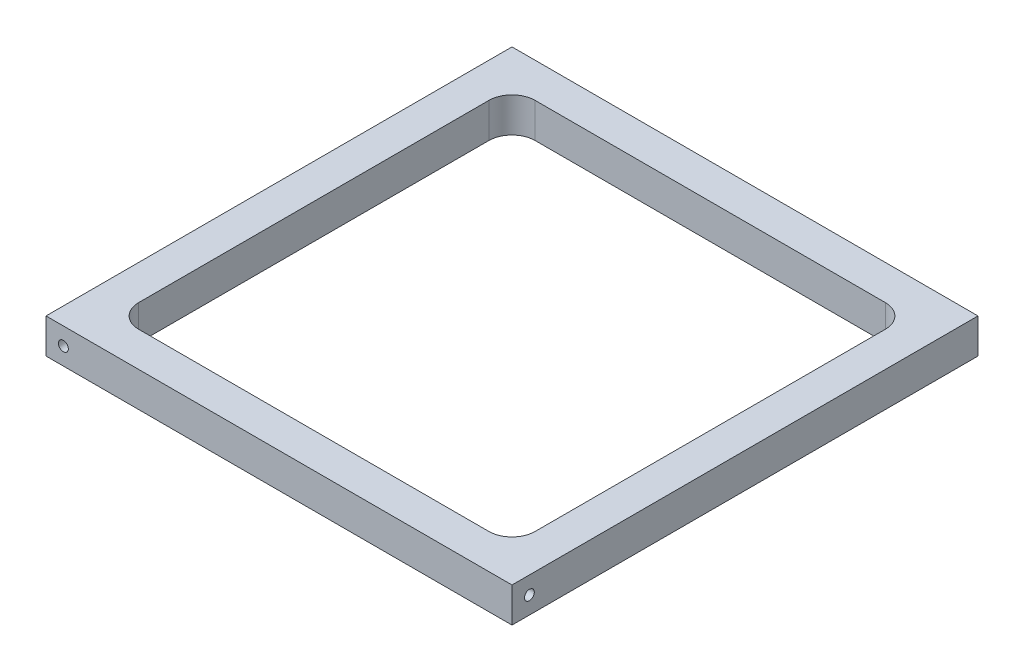
from build123d import *

# Parameters (mm, degrees)
SKETCH1_W                     = 127.635
SKETCH1_H                     = 127.635
BOSS_EXTRUDE1_DEPTH           = 9.525
SKETCH5_W                     = 108.585
SKETCH5_H                     = 108.585
CUT_EXTRUDE1_DEPTH            = 9.525
FILLET1_R                     = 6.35
TAP_DRILL_FOR_6_32_TAP2_D     = 2.7051
TAP_DRILL_FOR_6_32_TAP2_DEPTH = 12.7
TAP_DRILL_FOR_6_32_TAP2_TIP   = 0.81269403
TAP_DRILL_FOR_6_32_TAP3_D     = 2.7051
TAP_DRILL_FOR_6_32_TAP3_DEPTH = 12.7
TAP_DRILL_FOR_6_32_TAP3_TIP   = 0.81269403
TAP_DRILL_FOR_6_32_TAP4_D     = 2.7051
TAP_DRILL_FOR_6_32_TAP4_DEPTH = 12.7
TAP_DRILL_FOR_6_32_TAP4_TIP   = 0.81269403
TAP_DRILL_FOR_6_32_TAP5_D     = 2.7051
TAP_DRILL_FOR_6_32_TAP5_DEPTH = 12.7
TAP_DRILL_FOR_6_32_TAP5_TIP   = 0.81269403


with BuildPart() as part:
    # Sketch1 → Boss-Extrude1 (new body)
    with BuildSketch(Plane(origin=(0, 0, 0), x_dir=(1, 0, 0), z_dir=(0, 1, 0))):
        with Locations((63.8175, 63.8175)):
            Rectangle(SKETCH1_W, SKETCH1_H)
    extrude(amount=BOSS_EXTRUDE1_DEPTH)

    # Sketch5 → Cut-Extrude1 (cut)
    with BuildSketch(Plane(origin=(0, 9.525, 0), x_dir=(1, 0, 0), z_dir=(0, 1, 0))):
        with Locations((63.8175, 63.8175)):
            Rectangle(SKETCH5_W, SKETCH5_H)
    extrude(amount=-CUT_EXTRUDE1_DEPTH, mode=Mode.SUBTRACT)

    # Fillet1
    fillet1_edges = [part.edges().sort_by_distance(p)[0] for p in [
        (118.11, 4.7625, -9.525),
        (9.525, 4.7625, -9.525),
        (9.525, 4.7625, -118.11),
        (118.11, 4.7625, -118.11),
    ]]
    fillet(fillet1_edges, radius=FILLET1_R)

    # Tap Drill for #6-32 Tap2
    with Locations(Plane(origin=(127.635, 0, 0), x_dir=(0, 0, -1), z_dir=(1, 0, 0))):
        with Locations((4.7625, 4.7625)):
            Hole(TAP_DRILL_FOR_6_32_TAP2_D / 2, depth=TAP_DRILL_FOR_6_32_TAP2_DEPTH)
            with Locations((0, 0, -(TAP_DRILL_FOR_6_32_TAP2_DEPTH + TAP_DRILL_FOR_6_32_TAP2_TIP / 2))):  # 118° drill point
                Cone(0, TAP_DRILL_FOR_6_32_TAP2_D / 2, TAP_DRILL_FOR_6_32_TAP2_TIP, mode=Mode.SUBTRACT)

    # Tap Drill for #6-32 Tap3
    with Locations(Plane.XY):
        with Locations((4.7625, 4.7625)):
            Hole(TAP_DRILL_FOR_6_32_TAP3_D / 2, depth=TAP_DRILL_FOR_6_32_TAP3_DEPTH)
            with Locations((0, 0, -(TAP_DRILL_FOR_6_32_TAP3_DEPTH + TAP_DRILL_FOR_6_32_TAP3_TIP / 2))):  # 118° drill point
                Cone(0, TAP_DRILL_FOR_6_32_TAP3_D / 2, TAP_DRILL_FOR_6_32_TAP3_TIP, mode=Mode.SUBTRACT)

    # Tap Drill for #6-32 Tap4
    with Locations(Plane.ZY):
        with Locations((-122.8725, 4.7625)):
            Hole(TAP_DRILL_FOR_6_32_TAP4_D / 2, depth=TAP_DRILL_FOR_6_32_TAP4_DEPTH)
            with Locations((0, 0, -(TAP_DRILL_FOR_6_32_TAP4_DEPTH + TAP_DRILL_FOR_6_32_TAP4_TIP / 2))):  # 118° drill point
                Cone(0, TAP_DRILL_FOR_6_32_TAP4_D / 2, TAP_DRILL_FOR_6_32_TAP4_TIP, mode=Mode.SUBTRACT)

    # Tap Drill for #6-32 Tap5
    with Locations(Plane(origin=(0, 0, -127.635), x_dir=(-1, 0, 0), z_dir=(0, 0, -1))):
        with Locations((-122.8725, 4.7625)):
            Hole(TAP_DRILL_FOR_6_32_TAP5_D / 2, depth=TAP_DRILL_FOR_6_32_TAP5_DEPTH)
            with Locations((0, 0, -(TAP_DRILL_FOR_6_32_TAP5_DEPTH + TAP_DRILL_FOR_6_32_TAP5_TIP / 2))):  # 118° drill point
                Cone(0, TAP_DRILL_FOR_6_32_TAP5_D / 2, TAP_DRILL_FOR_6_32_TAP5_TIP, mode=Mode.SUBTRACT)


solid = part.part
